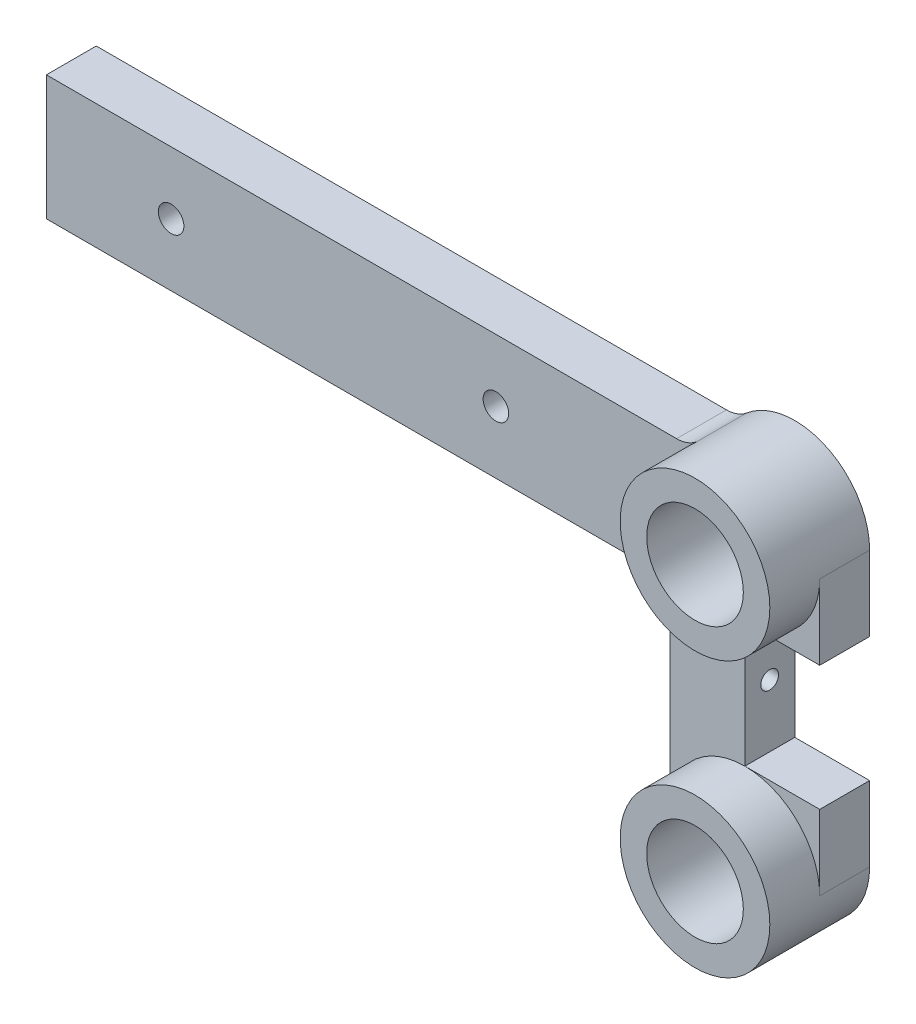
from build123d import *

# Parameters (mm, degrees)
BOSS_EXTRU_1_DEPTH                    = 8
ESQUISSE2_W                           = 8
ESQUISSE2_H                           = 20
BOSS_EXTRU_2_DEPTH                    = 100
BOSS_EXTRU_2_DEPTH_BACK               = 5
ESQUISSE3_R                           = 12
BOSS_EXTRU_3_DEPTH                    = 8
ESQUISSE4_R                           = 12
BOSS_EXTRU_4_DEPTH                    = 8
DIAM_TRE_DU_PER_AGE_4_1_4_1_1_D       = 4.1
DIAM_TRE_DU_PER_AGE_15_5_15_5_1_D     = 15.5
DIAM_TRE_DU_PER_AGE_15_5_15_5_1_DEPTH = 16
D_GAGEMENT_M2_51_D                    = 2.85
D_GAGEMENT_M2_51_DEPTH                = 10
CONG_1_R                              = 5


with BuildPart() as part:
    # Esquisse1 → Boss.-Extru.1 (new body)
    with BuildSketch(Plane.XY.offset(8)):
        with BuildLine():
            Line((-12, 44.000000179), (-12, 0))
            ThreePointArc((-12, 0), (0, -12), (12, 0))
            Line((12, 0), (12, 12))
            Line((12, 12), (0, 12))
            Line((0, 12), (0, 32))
            Line((0, 32), (12, 32))
            Line((12, 32), (12, 44.000000179))
            ThreePointArc((12, 44.000000179), (0, 56.000000179), (-12, 44.000000179))
        make_face()
    extrude(amount=-BOSS_EXTRU_1_DEPTH)

    # Esquisse2 → Boss.-Extru.2 (add, two sides)
    with BuildSketch(Plane.ZY.offset(12)) as boss_extru_2_sk:
        with Locations((4, 42)):
            Rectangle(ESQUISSE2_W, ESQUISSE2_H)
    extrude(amount=BOSS_EXTRU_2_DEPTH)
    extrude(boss_extru_2_sk.sketch, amount=-BOSS_EXTRU_2_DEPTH_BACK)

    # Esquisse3 → Boss.-Extru.3 (add)
    with BuildSketch(Plane.XY.offset(8)):
        with Locations((0, 44)):
            Circle(ESQUISSE3_R)
    extrude(amount=BOSS_EXTRU_3_DEPTH)

    # Esquisse4 → Boss.-Extru.4 (add)
    with BuildSketch(Plane.XY.offset(8)):
        Circle(ESQUISSE4_R)
    extrude(amount=BOSS_EXTRU_4_DEPTH)

    # Diamètre du perçage Ø4.1 (4.1)1 (through all)
    with Locations(Plane.XY.offset(8)):
        with Locations((-39.923806844, 42), (-92, 42)):
            Hole(DIAM_TRE_DU_PER_AGE_4_1_4_1_1_D / 2)

    # Diamètre du perçage Ø15.5 (15.5)1
    with Locations(Plane.XY.offset(16)):
        with Locations((0, 44), (0, 0)):
            Hole(DIAM_TRE_DU_PER_AGE_15_5_15_5_1_D / 2, depth=DIAM_TRE_DU_PER_AGE_15_5_15_5_1_DEPTH)

    # Dégagement M2.51
    with Locations(Plane(origin=(0, 0, 0), x_dir=(0, 0, -1), z_dir=(1, 0, 0))):
        with Locations((-4.029990313, 22)):
            Hole(D_GAGEMENT_M2_51_D / 2, depth=D_GAGEMENT_M2_51_DEPTH)

    # Congé1
    cong_1_edges = [part.edges().sort_by_distance(p)[0] for p in [
        (-8.94427207, 52, 4),
        (-12, 32, 4),
    ]]
    fillet(cong_1_edges, radius=CONG_1_R)


solid = part.part
